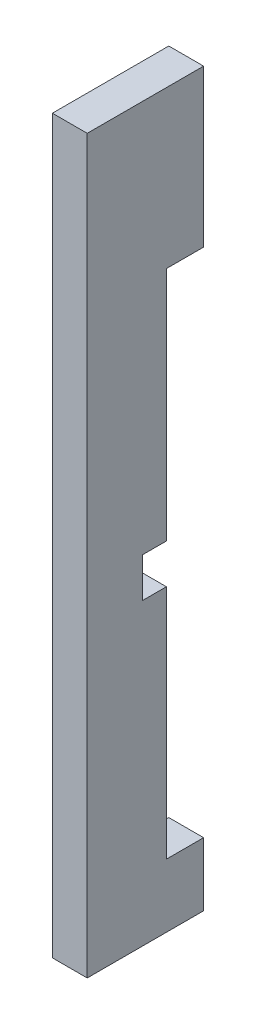
from build123d import *

# Parameters (mm, degrees)
ESQUISSE1_W             = 22
ESQUISSE1_H             = 462
BOSS_EXTRU_1_DEPTH      = 73.5
ESQUISSE2_W             = 38.5
ESQUISSE2_H             = 25
ENL_V_MAT_EXTRU_1_DEPTH = 35
ESQUISSE3_W             = 23.5
ESQUISSE3_H             = 323
ENL_V_MAT_EXTRU_2_DEPTH = 35


with BuildPart() as part:
    # Esquisse1 → Boss.-Extru.1 (new body)
    with BuildSketch(Plane.XY):
        with Locations((129, 30)):
            Rectangle(ESQUISSE1_W, ESQUISSE1_H)
    extrude(amount=BOSS_EXTRU_1_DEPTH)

    # Esquisse2 → Enlèv. mat.-Extru.1 (cut)
    with BuildSketch(Plane.ZY.offset(-118)):
        with Locations((19.25, 0.5)):
            Rectangle(ESQUISSE2_W, ESQUISSE2_H)
    extrude(amount=-ENL_V_MAT_EXTRU_1_DEPTH, mode=Mode.SUBTRACT)

    # Esquisse3 → Enlèv. mat.-Extru.2 (cut)
    with BuildSketch(Plane(origin=(140, 0, 0), x_dir=(0, 0, -1), z_dir=(1, 0, 0))):
        with Locations((-11.75, 0.5)):
            Rectangle(ESQUISSE3_W, ESQUISSE3_H)
    extrude(amount=-ENL_V_MAT_EXTRU_2_DEPTH, mode=Mode.SUBTRACT)


solid = part.part
